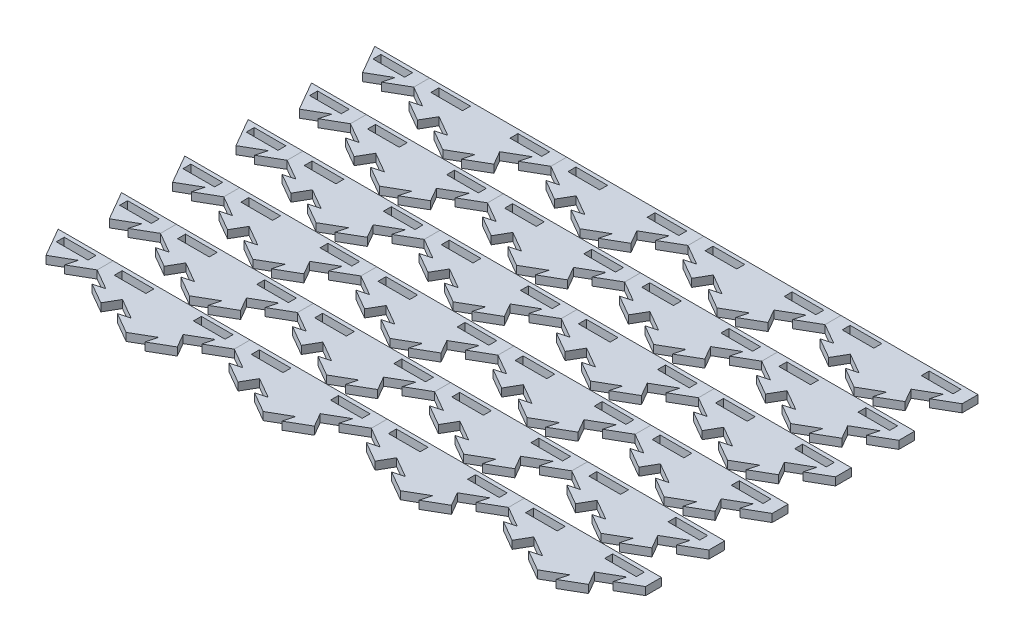
from build123d import *

# Parameters (mm, degrees)
BOSS_EXTRUDE1_DEPTH = 6.35
CUT_EXTRUDE4_DEPTH  = 111.168382488
BOSS_EXTRUDE4_DEPTH = 6.35
CIRPATTERN1_COUNT   = 2
CIRPATTERN1_ANGLE   = 60
SKETCH12_W          = 109.98522628
SKETCH12_H          = 82.55
CUT_EXTRUDE5_DEPTH  = 111.168382488
SKETCH13_W          = 25.4
SKETCH13_H          = 6.35
CUT_EXTRUDE6_DEPTH  = 64.816710194
LPATTERN1_COUNT     = 5
LPATTERN1_PITCH     = 109.985226308
LPATTERN1_2_COUNT   = 2
LPATTERN1_2_PITCH   = 109.985226308
SKETCH14_W          = 25.4
SKETCH14_H          = 6.35
CUT_EXTRUDE7_DEPTH  = 496.991504573
SKETCH15_W          = 43.994090512
SKETCH15_H          = 34.074261314
CUT_EXTRUDE8_DEPTH  = 431.162704792
LPATTERN2_COUNT     = 6
LPATTERN2_PITCH     = 50.8


with BuildPart() as part:
    # Sketch1 → Boss-Extrude1 (new body)
    with BuildSketch(Plane(origin=(0, 0, 0), x_dir=(1, 0, 0), z_dir=(0, 1, 0))):
        Polygon((-54.99261314, 0), (0, -31.75), (54.99261314, 0), (54.99261314, 63.5), (0, 95.25), (-54.99261314, 63.5), align=None)
    extrude(amount=-BOSS_EXTRUDE1_DEPTH)

    # Sketch10 → Cut-Extrude4 (cut, through all)
    with BuildSketch(Plane(origin=(0, 0, 0), x_dir=(1, 0, 0), z_dir=(0, 1, 0))):
        Polygon((-16.497783942, -22.225), (-7.823522628, -19.900738686), (-24.32130657, -10.375738686), (-27.49630657, -15.875), align=None)
    cut_extrude4 = extrude(amount=-CUT_EXTRUDE4_DEPTH, mode=Mode.SUBTRACT)

    # Sketch11 → Boss-Extrude4 (add)
    with BuildSketch(Plane(origin=(0, 0, 0), x_dir=(1, 0, 0), z_dir=(0, 1, 0))):
        Polygon((-27.49630657, -15.875), (-30.67130657, -21.374261314), (-47.169090512, -11.849261314), (-38.494829198, -9.525), align=None)
    boss_extrude4 = extrude(amount=-BOSS_EXTRUDE4_DEPTH)

    # CirPattern1: Cut-Extrude4, Boss-Extrude4 ×2 about axis
    cirpattern1_axis = Axis((0, 0, -31.75), (0, 1, 0))
    add([cut_extrude4.rotate(cirpattern1_axis, i * CIRPATTERN1_ANGLE / (CIRPATTERN1_COUNT - 1)) for i in range(1, CIRPATTERN1_COUNT)], mode=Mode.SUBTRACT)
    add([boss_extrude4.rotate(cirpattern1_axis, i * CIRPATTERN1_ANGLE / (CIRPATTERN1_COUNT - 1)) for i in range(1, CIRPATTERN1_COUNT)])

    # Sketch12 → Cut-Extrude5 (cut, through all)
    with BuildSketch(Plane(origin=(0, 0, 0), x_dir=(1, 0, 0), z_dir=(0, 1, 0))):
        with Locations((0, 53.975)):
            Rectangle(SKETCH12_W, SKETCH12_H)
    extrude(amount=-CUT_EXTRUDE5_DEPTH, mode=Mode.SUBTRACT)

    # Sketch13 → Cut-Extrude6 (cut, through all)
    with BuildSketch(Plane(origin=(0, 0, 0), x_dir=(1, 0, 0), z_dir=(0, 1, 0))):
        with Locations((-31.75, 6.35)):
            Rectangle(SKETCH13_W, SKETCH13_H)
        with Locations((31.75, 6.35)):
            Rectangle(SKETCH13_W, SKETCH13_H)
    extrude(amount=-CUT_EXTRUDE6_DEPTH, mode=Mode.SUBTRACT)


with BuildPart() as lpattern1_1:
    # LPattern1: pattern copy
    add(part.part.moved(Location(Vector(1, 0, 0) * (1 * LPATTERN1_PITCH))))


with BuildPart() as lpattern1_2:
    # LPattern1: pattern copy
    add(part.part.moved(Location(Vector(1, 0, 0) * (2 * LPATTERN1_PITCH))))


with BuildPart() as lpattern1_3:
    # LPattern1: pattern copy
    add(part.part.moved(Location(Vector(1, 0, 0) * (3 * LPATTERN1_PITCH))))


with BuildPart() as lpattern1_4:
    # LPattern1: pattern copy
    add(part.part.moved(Location(Vector(1, 0, 0) * (4 * LPATTERN1_PITCH))))


with BuildPart() as lpattern1_2_1:
    # LPattern1 2: pattern copy
    add(part.part.moved(Location(Vector(-1, 0, 0) * (1 * LPATTERN1_2_PITCH))))


with BuildPart() as cut_extrude7_tool:
    # Sketch14 → Cut-Extrude7 (new, through all)
    # profile 1 of 2: a face of its own
    with BuildSketch(Plane(origin=(0, 0, 0), x_dir=(1, 0, 0), z_dir=(0, 1, 0))):
        Polygon((423.44312129, -22.225), (439.940905232, -31.75), (456.438689174, -22.225), (454.11442786, -30.899261314), (470.612211802, -21.374261314), (464.262211802, -10.375738686), (480.759995744, -0.850738686), (478.43573443, -9.525), (494.933518372, 0), (494.933518372, 12.7), (428.942382604, 12.7), (415.619598662, -10.375738686), (432.117382604, -19.900738686), align=None)
        with Locations((471.690905232, 6.35)):
            Rectangle(SKETCH14_W, SKETCH14_H, mode=Mode.SUBTRACT)
    # profile 2 of 2: a face of its own
    with BuildSketch(Plane(origin=(0, 0, 0), x_dir=(1, 0, 0), z_dir=(0, 1, 0))):
        Polygon((-164.977839448, -31.75), (-109.985226308, -31.75), (-95.81170368, -30.899261314), (-79.313919738, -21.374261314), (-98.98670368, 12.7), (-164.977839448, 12.7), align=None)
    extrude(amount=-CUT_EXTRUDE7_DEPTH)


with BuildPart() as lpattern1_4_1:
    add(lpattern1_4.part)

    # Cut-Extrude7: cut by cut_extrude7_tool
    add(cut_extrude7_tool.part, mode=Mode.SUBTRACT)

    # Sketch15 → Cut-Extrude8 (cut, through all)
    with BuildSketch(Plane(origin=(0, 0, 0), x_dir=(1, 0, 0), z_dir=(0, 1, 0))):
        with Locations((406.945337348, -4.337130657)):
            Rectangle(SKETCH15_W, SKETCH15_H)
    extrude(amount=-CUT_EXTRUDE8_DEPTH, mode=Mode.SUBTRACT)


with BuildPart() as lpattern1_2_1_1:
    add(lpattern1_2_1.part)

    # Cut-Extrude7: cut by cut_extrude7_tool
    add(cut_extrude7_tool.part, mode=Mode.SUBTRACT)


with BuildPart() as lpattern2_1:
    # LPattern2: pattern copy
    add(lpattern1_2_1_1.part.moved(Location(Vector(0, 0, 1) * (1 * LPATTERN2_PITCH))))


with BuildPart() as lpattern2_2:
    # LPattern2: pattern copy
    add(lpattern1_2_1_1.part.moved(Location(Vector(0, 0, 1) * (2 * LPATTERN2_PITCH))))


with BuildPart() as lpattern2_3:
    # LPattern2: pattern copy
    add(lpattern1_2_1_1.part.moved(Location(Vector(0, 0, 1) * (3 * LPATTERN2_PITCH))))


with BuildPart() as lpattern2_4:
    # LPattern2: pattern copy
    add(lpattern1_2_1_1.part.moved(Location(Vector(0, 0, 1) * (4 * LPATTERN2_PITCH))))


with BuildPart() as lpattern2_5:
    # LPattern2: pattern copy
    add(lpattern1_2_1_1.part.moved(Location(Vector(0, 0, 1) * (5 * LPATTERN2_PITCH))))


with BuildPart() as lpattern2_6:
    # LPattern2: pattern copy
    add(part.part.moved(Location(Vector(0, 0, 1) * (1 * LPATTERN2_PITCH))))


with BuildPart() as lpattern2_7:
    # LPattern2: pattern copy
    add(part.part.moved(Location(Vector(0, 0, 1) * (2 * LPATTERN2_PITCH))))


with BuildPart() as lpattern2_8:
    # LPattern2: pattern copy
    add(part.part.moved(Location(Vector(0, 0, 1) * (3 * LPATTERN2_PITCH))))


with BuildPart() as lpattern2_9:
    # LPattern2: pattern copy
    add(part.part.moved(Location(Vector(0, 0, 1) * (4 * LPATTERN2_PITCH))))


with BuildPart() as lpattern2_10:
    # LPattern2: pattern copy
    add(part.part.moved(Location(Vector(0, 0, 1) * (5 * LPATTERN2_PITCH))))


with BuildPart() as lpattern2_11:
    # LPattern2: pattern copy
    add(lpattern1_1.part.moved(Location(Vector(0, 0, 1) * (1 * LPATTERN2_PITCH))))


with BuildPart() as lpattern2_12:
    # LPattern2: pattern copy
    add(lpattern1_1.part.moved(Location(Vector(0, 0, 1) * (2 * LPATTERN2_PITCH))))


with BuildPart() as lpattern2_13:
    # LPattern2: pattern copy
    add(lpattern1_1.part.moved(Location(Vector(0, 0, 1) * (3 * LPATTERN2_PITCH))))


with BuildPart() as lpattern2_14:
    # LPattern2: pattern copy
    add(lpattern1_1.part.moved(Location(Vector(0, 0, 1) * (4 * LPATTERN2_PITCH))))


with BuildPart() as lpattern2_15:
    # LPattern2: pattern copy
    add(lpattern1_1.part.moved(Location(Vector(0, 0, 1) * (5 * LPATTERN2_PITCH))))


with BuildPart() as lpattern2_16:
    # LPattern2: pattern copy
    add(lpattern1_2.part.moved(Location(Vector(0, 0, 1) * (1 * LPATTERN2_PITCH))))


with BuildPart() as lpattern2_17:
    # LPattern2: pattern copy
    add(lpattern1_2.part.moved(Location(Vector(0, 0, 1) * (2 * LPATTERN2_PITCH))))


with BuildPart() as lpattern2_18:
    # LPattern2: pattern copy
    add(lpattern1_2.part.moved(Location(Vector(0, 0, 1) * (3 * LPATTERN2_PITCH))))


with BuildPart() as lpattern2_19:
    # LPattern2: pattern copy
    add(lpattern1_2.part.moved(Location(Vector(0, 0, 1) * (4 * LPATTERN2_PITCH))))


with BuildPart() as lpattern2_20:
    # LPattern2: pattern copy
    add(lpattern1_2.part.moved(Location(Vector(0, 0, 1) * (5 * LPATTERN2_PITCH))))


with BuildPart() as lpattern2_21:
    # LPattern2: pattern copy
    add(lpattern1_3.part.moved(Location(Vector(0, 0, 1) * (1 * LPATTERN2_PITCH))))


with BuildPart() as lpattern2_22:
    # LPattern2: pattern copy
    add(lpattern1_3.part.moved(Location(Vector(0, 0, 1) * (2 * LPATTERN2_PITCH))))


with BuildPart() as lpattern2_23:
    # LPattern2: pattern copy
    add(lpattern1_3.part.moved(Location(Vector(0, 0, 1) * (3 * LPATTERN2_PITCH))))


with BuildPart() as lpattern2_24:
    # LPattern2: pattern copy
    add(lpattern1_3.part.moved(Location(Vector(0, 0, 1) * (4 * LPATTERN2_PITCH))))


with BuildPart() as lpattern2_25:
    # LPattern2: pattern copy
    add(lpattern1_3.part.moved(Location(Vector(0, 0, 1) * (5 * LPATTERN2_PITCH))))


solid = Compound([part.part, lpattern1_1.part, lpattern1_2.part, lpattern1_3.part, lpattern1_2_1_1.part, lpattern2_1.part, lpattern2_2.part, lpattern2_3.part, lpattern2_4.part, lpattern2_5.part, lpattern2_6.part, lpattern2_7.part, lpattern2_8.part, lpattern2_9.part, lpattern2_10.part, lpattern2_11.part, lpattern2_12.part, lpattern2_13.part, lpattern2_14.part, lpattern2_15.part, lpattern2_16.part, lpattern2_17.part, lpattern2_18.part, lpattern2_19.part, lpattern2_20.part, lpattern2_21.part, lpattern2_22.part, lpattern2_23.part, lpattern2_24.part, lpattern2_25.part])
